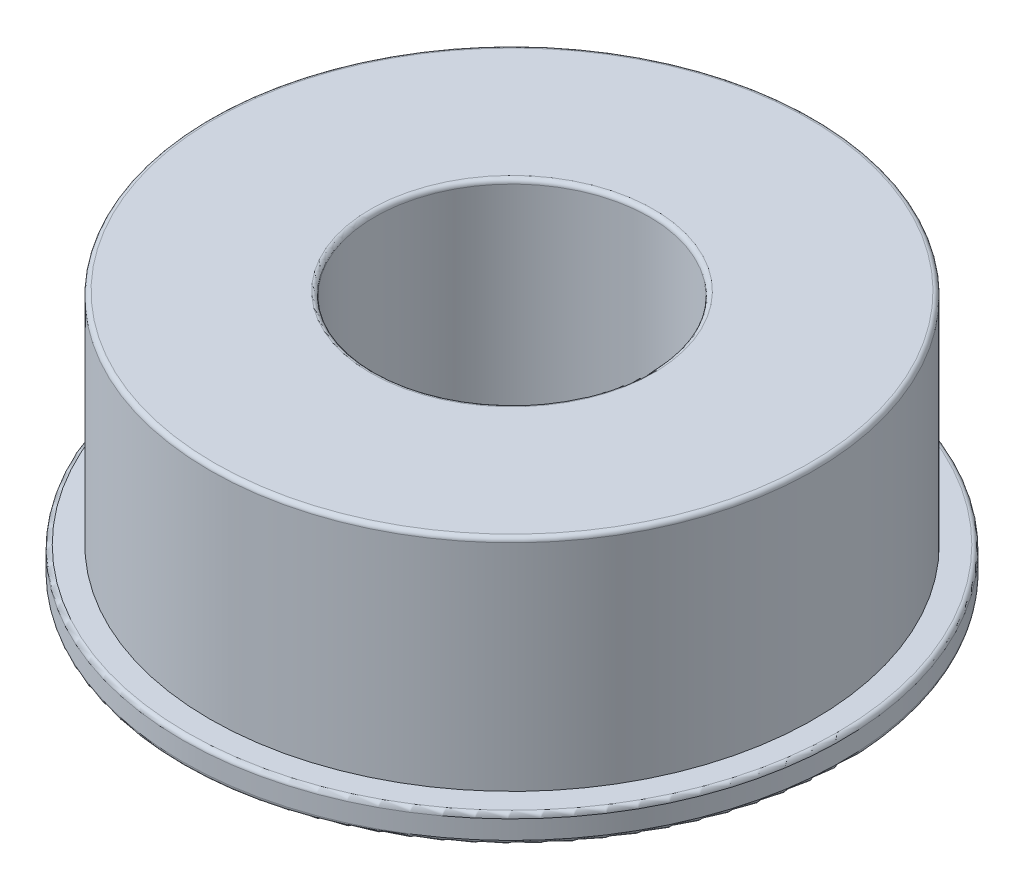
from build123d import *

# Parameters (mm, degrees)
SKETCH1_R           = 19.05
BOSS_EXTRUDE1_DEPTH = 1.5875
SKETCH2_R           = 17.4625
BOSS_EXTRUDE2_DEPTH = 12.7
SKETCH3_R           = 7.9375
CUT_EXTRUDE1_DEPTH  = 15.2875
FILLET1_R           = 0.254


with BuildPart() as part:
    # Sketch1 → Boss-Extrude1 (new body)
    with BuildSketch(Plane(origin=(0, 0, 0), x_dir=(1, 0, 0), z_dir=(0, 1, 0))):
        Circle(SKETCH1_R)
    extrude(amount=BOSS_EXTRUDE1_DEPTH)

    # Sketch2 → Boss-Extrude2 (add)
    with BuildSketch(Plane(origin=(0, 1.5875, 0), x_dir=(1, 0, 0), z_dir=(0, 1, 0))):
        Circle(SKETCH2_R)
    extrude(amount=BOSS_EXTRUDE2_DEPTH)

    # Sketch3 → Cut-Extrude1 (cut, through all)
    with BuildSketch(Plane(origin=(0, 14.2875, 0), x_dir=(1, 0, 0), z_dir=(0, 1, 0))):
        Circle(SKETCH3_R)
    extrude(amount=-CUT_EXTRUDE1_DEPTH, mode=Mode.SUBTRACT)

    # Fillet1
    fillet1_edges = [part.edges().sort_by_distance(p)[0] for p in [
        (-7.9375, 14.2875, 0),
        (-19.05, 0, 0),
        (-19.05, 1.5875, 0),
        (-17.4625, 14.2875, 0),
    ]]
    fillet(fillet1_edges, radius=FILLET1_R)


solid = part.part
